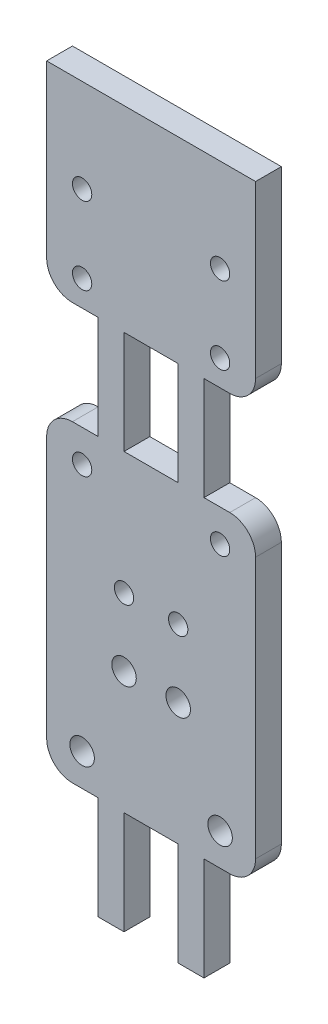
from build123d import *

# Parameters (mm, degrees)
SKETCH1_R           = 0.75
SKETCH1_R_2         = 0.95
SKETCH1_W           = 4.2
SKETCH1_H           = 8
BOSS_EXTRUDE1_DEPTH = 2


with BuildPart() as part:
    # Sketch1 → Boss-Extrude1 (new body)
    with BuildSketch(Plane.XY):
        with BuildLine():
            Line((4, 44.7), (4, 52.7))
            Line((4, 52.7), (2, 52.7))
            ThreePointArc((2, 52.7), (0.585786438, 53.285786438), (0, 54.7))
            Line((0, 54.7), (0, 67.93))
            Line((0, 67.93), (16.2, 67.93))
            Line((16.2, 67.93), (16.2, 54.7))
            ThreePointArc((16.2, 54.7), (15.614213562, 53.285786438), (14.2, 52.7))
            Line((14.2, 52.7), (12.2, 52.7))
            Line((12.2, 52.7), (12.2, 44.7))
            Line((12.2, 44.7), (14.2, 44.7))
            ThreePointArc((14.2, 44.7), (15.614213562, 44.114213562), (16.2, 42.7))
            Line((16.2, 42.7), (16.2, 22.44))
            ThreePointArc((16.2, 22.44), (15.614213562, 21.025786438), (14.2, 20.44))
            Line((14.2, 20.44), (12.2, 20.44))
            Line((12.2, 20.44), (12.2, 12.44))
            Line((12.2, 12.44), (10.2, 12.44))
            Line((10.2, 12.44), (10.2, 20.44))
            Line((10.2, 20.44), (6, 20.44))
            Line((6, 20.44), (6, 12.44))
            Line((6, 12.44), (4, 12.44))
            Line((4, 12.44), (4, 20.44))
            Line((4, 20.44), (2, 20.44))
            ThreePointArc((2, 20.44), (0.585786438, 21.025786438), (0, 22.44))
            Line((0, 22.44), (0, 42.7))
            ThreePointArc((0, 42.7), (0.585786438, 44.114213562), (2, 44.7))
            Line((2, 44.7), (4, 44.7))
        make_face()
        with Locations((2.75, 60.7)):
            Circle(SKETCH1_R, mode=Mode.SUBTRACT)
        with Locations((13.45, 54.7)):
            Circle(SKETCH1_R, mode=Mode.SUBTRACT)
        with Locations((13.45, 42.2)):
            Circle(SKETCH1_R, mode=Mode.SUBTRACT)
        with Locations((13.45, 22.94)):
            Circle(SKETCH1_R_2, mode=Mode.SUBTRACT)
        with Locations((10.2, 29.94)):
            Circle(SKETCH1_R_2, mode=Mode.SUBTRACT)
        with Locations((6, 35.2)):
            Circle(SKETCH1_R, mode=Mode.SUBTRACT)
        with Locations((13.45, 60.7)):
            Circle(SKETCH1_R, mode=Mode.SUBTRACT)
        with Locations((10.2, 35.2)):
            Circle(SKETCH1_R, mode=Mode.SUBTRACT)
        with Locations((6, 29.94)):
            Circle(SKETCH1_R_2, mode=Mode.SUBTRACT)
        with Locations((2.75, 22.94)):
            Circle(SKETCH1_R_2, mode=Mode.SUBTRACT)
        with Locations((2.75, 42.2)):
            Circle(SKETCH1_R, mode=Mode.SUBTRACT)
        with Locations((2.75, 54.7)):
            Circle(SKETCH1_R, mode=Mode.SUBTRACT)
        with Locations((8.1, 48.7)):
            Rectangle(SKETCH1_W, SKETCH1_H, mode=Mode.SUBTRACT)
    extrude(amount=BOSS_EXTRUDE1_DEPTH)


solid = part.part
